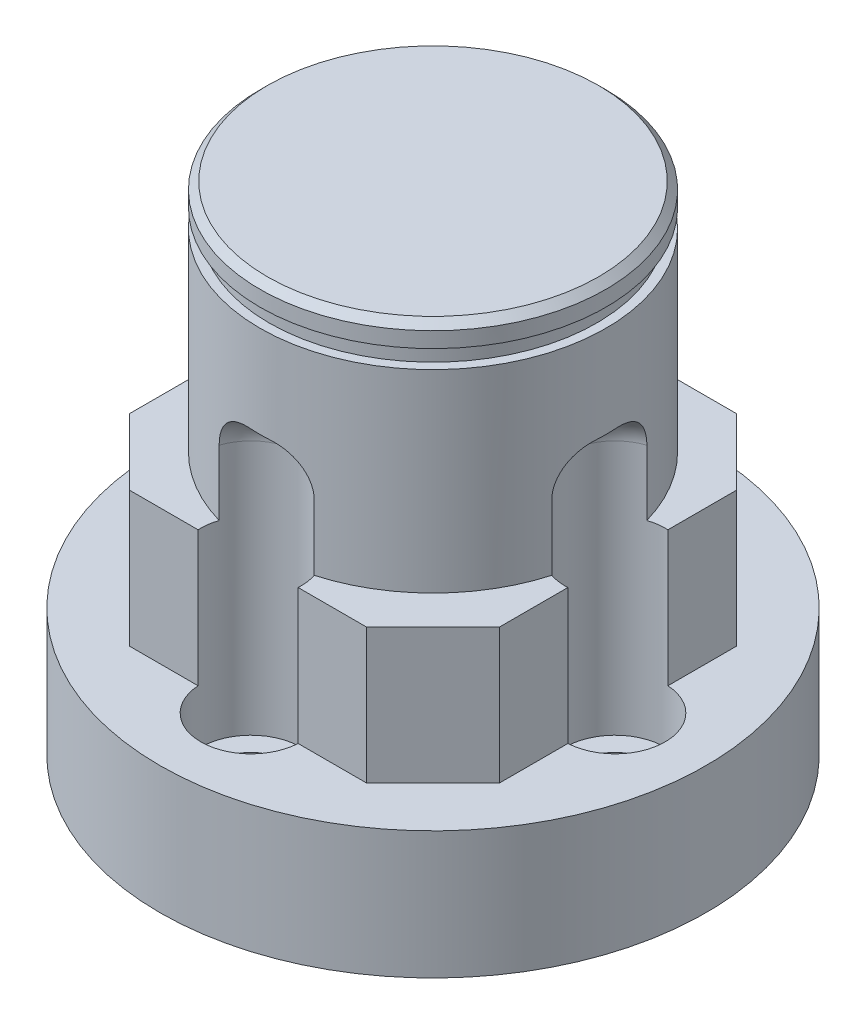
from build123d import *
from build123d.topology import SkipClean

# Parameters (mm, degrees)
SKETCH1_R           = 15
SKETCH1_R_2         = 1.6
BOSS_EXTRUDE1_DEPTH = 7
BOSS_EXTRUDE2_DEPTH = 7.42
SKETCH3_R           = 9.5
BOSS_EXTRUDE3_DEPTH = 12.88
SKETCH5_R           = 1.6
CUT_EXTRUDE1_DEPTH  = 20
SKETCH6_R           = 2.75
CUT_EXTRUDE2_DEPTH  = 16
FILLET1_R           = 2
CHAMFER1_SIZE       = 0.4


with BuildPart() as part:
    # Sketch1 → Boss-Extrude1 (new body)
    with BuildSketch(Plane(origin=(0, 0, 0), x_dir=(1, 0, 0), z_dir=(0, 1, 0))):
        with Locations(Location((0, 0, 0), (0, 0, 270))):
            Circle(SKETCH1_R)
        with Locations(Location((0, 10, 0), (0, 0, 270))):
            Circle(SKETCH1_R_2, mode=Mode.SUBTRACT)
        with Locations(Location((0, -10, 0), (0, 0, 270))):
            Circle(SKETCH1_R_2, mode=Mode.SUBTRACT)
        with Locations(Location((10, 0, 0), (0, 0, 270))):
            Circle(SKETCH1_R_2, mode=Mode.SUBTRACT)
        with Locations(Location((-10, 0, 0), (0, 0, 270))):
            Circle(SKETCH1_R_2, mode=Mode.SUBTRACT)
    extrude(amount=BOSS_EXTRUDE1_DEPTH)

    # Sketch2 → Boss-Extrude2 (add)
    with BuildSketch(Plane(origin=(0, 7, 0), x_dir=(1, 0, 0), z_dir=(0, 1, 0))):
        Polygon((-6.505, 10.155), (6.505, 10.155), (10.155, 6.505), (10.155, -6.505), (6.505, -10.155), (-6.505, -10.155), (-10.155, -6.505), (-10.155, 6.505), align=None)
    extrude(amount=BOSS_EXTRUDE2_DEPTH)

    # Sketch3 → Boss-Extrude3 (add)
    with BuildSketch(Plane(origin=(0, 14.42, 0), x_dir=(1, 0, 0), z_dir=(0, 1, 0))):
        with Locations(Location((0, 0, 0), (0, 0, 90))):
            Circle(SKETCH3_R)
    extrude(amount=BOSS_EXTRUDE3_DEPTH)

    # Sketch4 → Cut-Revolve1 (revolve, cut)
    with BuildSketch(Plane.XY, mode=Mode.PRIVATE) as cut_revolve1_sk:
        Polygon((9, 25.05), (10, 25.05), (10, 26.05), (9.5, 26.05), (9, 25.761324865), align=None)
    revolve(cut_revolve1_sk.sketch.rotate(Axis((0, 27.3, 0), (0, -1, 0)), 270), axis=Axis((0, 27.3, 0), (0, -1, 0)), mode=Mode.SUBTRACT)

    # Sketch5 → Cut-Extrude1 (cut)
    with SkipClean():  # the faces are left unmerged after this step: merging them gives an invalid solid
        with BuildSketch(Plane.XZ):
            with Locations(Location((0, -10, 0), (0, 0, 185.559247246))):
                Circle(SKETCH5_R)
            with Locations(Location((10, 0, 0), (0, 0, 275.559247246))):
                Circle(SKETCH5_R)
            with Locations(Location((-10, 0, 0), (0, 0, 264.440752754))):
                Circle(SKETCH5_R)
            with Locations(Location((0, 10, 0), (0, 0, 202.624341254))):
                Circle(SKETCH5_R)
        extrude(amount=-CUT_EXTRUDE1_DEPTH, mode=Mode.SUBTRACT)

    # Sketch6 → Cut-Extrude2 (cut)
    with BuildSketch(Plane.XZ.offset(-20)):
        with Locations(Location((10, 0, 0), (0, 0, 90))):
            Circle(SKETCH6_R)
        with Locations(Location((0, 10, 0), (0, 0, 90))):
            Circle(SKETCH6_R)
        with Locations(Location((-10, 0, 0), (0, 0, 90))):
            Circle(SKETCH6_R)
        with Locations(Location((0, -10, 0), (0, 0, 90))):
            Circle(SKETCH6_R)
    extrude(amount=CUT_EXTRUDE2_DEPTH, mode=Mode.SUBTRACT)

    # Fillet1
    fillet1_edges = [part.edges().sort_by_distance(p)[0] for p in [
        (7.25, 20, 0),
        (0, 20, 7.25),
        (-7.25, 20, 0),
        (-1.609663202, 20, -7.770317427),
    ]]
    fillet(fillet1_edges, radius=FILLET1_R)

    # Chamfer1
    chamfer1_edges = [part.edges().sort_by_distance(p)[0] for p in [
        (0, 27.3, 9.5),
    ]]
    chamfer(chamfer1_edges, length=CHAMFER1_SIZE)


solid = part.part
